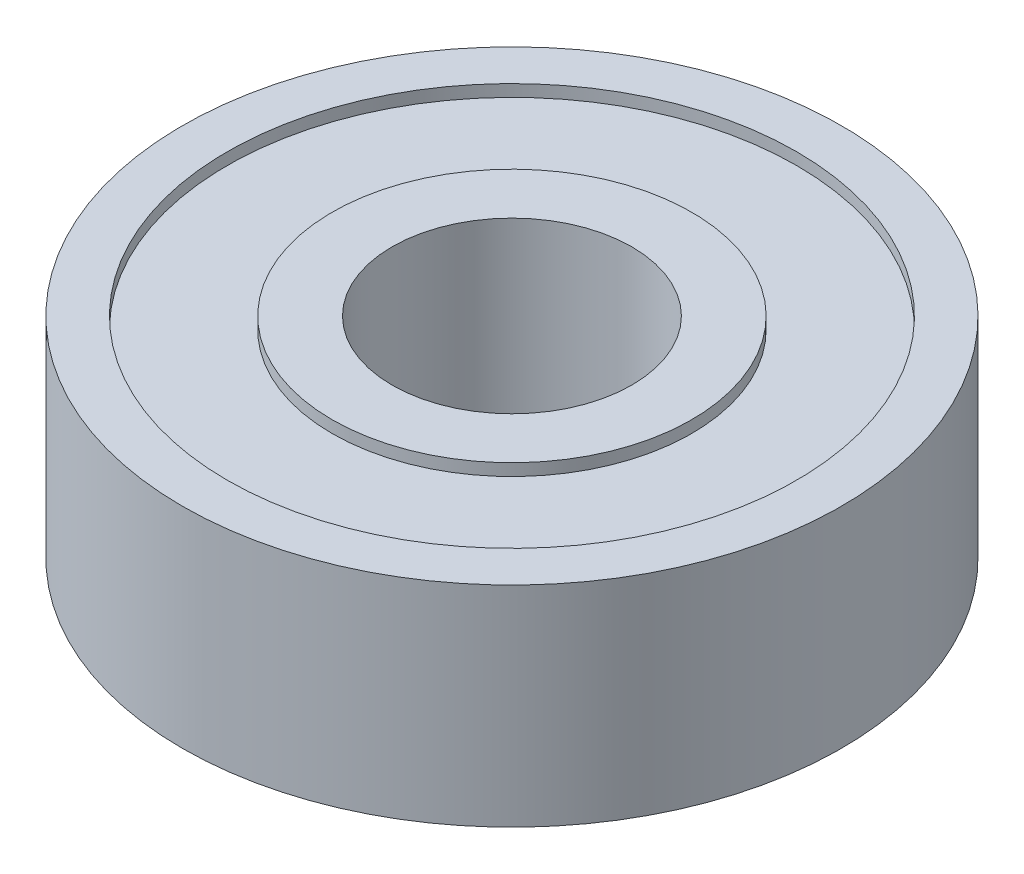
from build123d import *

# Parameters (mm, degrees)
SKETCH_1_R          = 11
SKETCH_1_R_2        = 4
EXTRUDE_1_DEPTH     = 3.5
CUT_EXTRUDE_START   = 3.5
SKETCH_2_R          = 9.5
SKETCH_2_R_2        = 6
CUT_EXTRUDE_1_DEPTH = 0.4


with BuildPart() as part:
    # 草圖1 → 填料-伸長1 (new body, symmetric)
    with BuildSketch(Plane(origin=(0, 0, 0), x_dir=(1, 0, 0), z_dir=(0, 1, 0))):
        Circle(SKETCH_1_R)
        Circle(SKETCH_1_R_2, mode=Mode.SUBTRACT)
    extrude(amount=EXTRUDE_1_DEPTH, both=True)

    # 草圖2 → 除料-伸長1 (cut)
    with BuildSketch(Plane(origin=(0, 0, 0), x_dir=(1, 0, 0), z_dir=(0, 1, 0)).offset(CUT_EXTRUDE_START)):
        Circle(SKETCH_2_R)
        Circle(SKETCH_2_R_2, mode=Mode.SUBTRACT)
    cut_extrude_1 = extrude(amount=-CUT_EXTRUDE_1_DEPTH, mode=Mode.SUBTRACT)

    # 鏡射4: 除料-伸長1 across plane
    add(cut_extrude_1.mirror(Plane.ZX), mode=Mode.SUBTRACT)


solid = part.part
